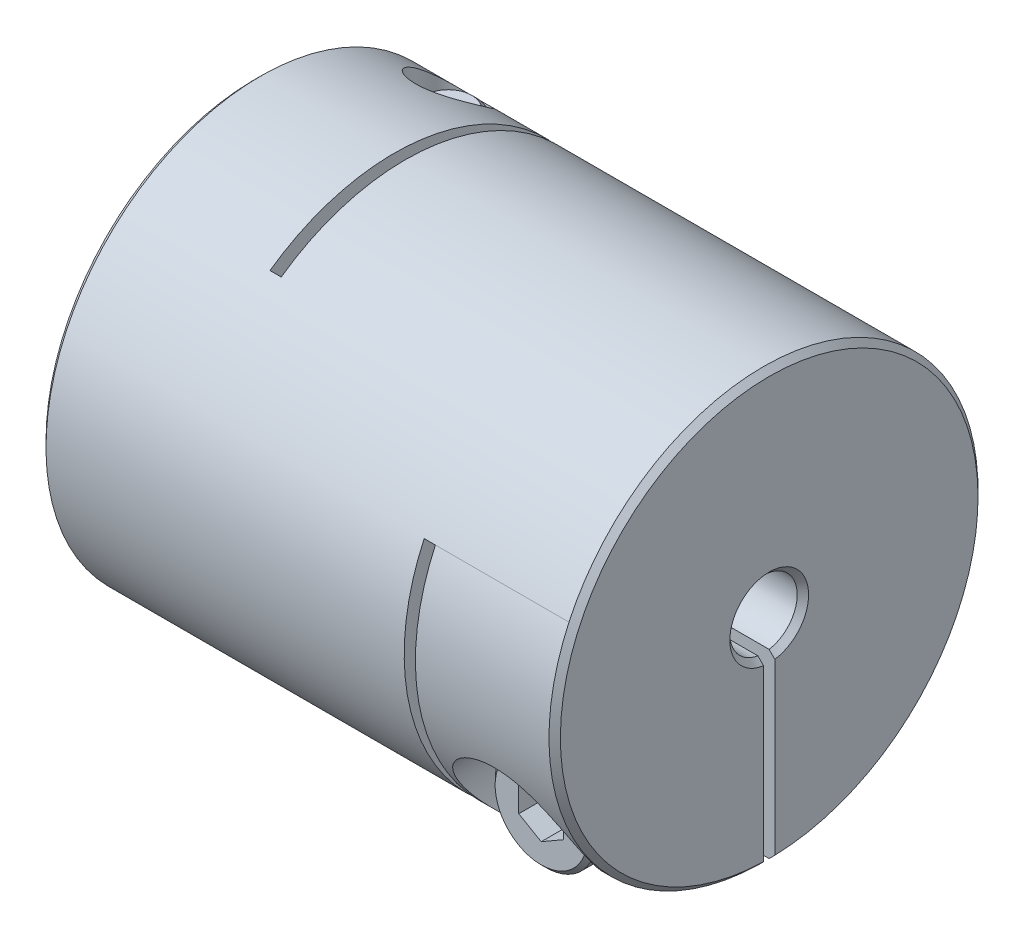
from build123d import *

# Parameters (mm, degrees)
SKETCH1_R                        = 9.55
BOSS_EXTRUDE1_DEPTH              = 11.45
SKETCH2_R                        = 1.5
CUT_EXTRUDE1_DEPTH               = 23.9
CHAMFER1_SIZE                    = 0.254
SKETCH4_W                        = 0.5
SKETCH4_H                        = 15.075
CUT_EXTRUDE2_DEPTH               = 20.1
SKETCH7_W                        = 0.5
SKETCH7_H                        = 13.575
CUT_EXTRUDE3_DEPTH               = 20.1
SKETCH8_W                        = 6.2
SKETCH8_H                        = 9.55
CUT_EXTRUDE5_DEPTH               = 0.25
SKETCH13_W                       = 6.2
SKETCH13_H                       = 9.55
CUT_EXTRUDE6_DEPTH               = 0.25
CBORE_FOR_M2_5_SHCS1_D           = 2.9
CBORE_FOR_M2_5_SHCS1_CBORE_D     = 5.5
CBORE_FOR_M2_5_SHCS1_CBORE_DEPTH = 5
CBORE_FOR_M2_5_SHCS2_D           = 2.9
CBORE_FOR_M2_5_SHCS2_CBORE_D     = 5.5
CBORE_FOR_M2_5_SHCS2_CBORE_DEPTH = 5
SKETCH16_R                       = 2.25
BOSS_EXTRUDE2_DEPTH              = 2.5
SKETCH17_R                       = 1.25
BOSS_EXTRUDE3_DEPTH              = 11.5
CHAMFER2_SIZE                    = 0.2
CUT_EXTRUDE7_DEPTH               = 1.5
CIRPATTERN1_COUNT                = 2
CIRPATTERN1_ANGLE                = 90


with BuildPart() as part:
    # Sketch1 → Boss-Extrude1 (new body, symmetric)
    with BuildSketch(Plane(origin=(0, 0, 0), x_dir=(0, 0, -1), z_dir=(1, 0, 0))):
        Circle(SKETCH1_R)
    extrude(amount=BOSS_EXTRUDE1_DEPTH, both=True)

    # Sketch2 → Cut-Extrude1 (cut, through all)
    with BuildSketch(Plane(origin=(11.45, 0, 0), x_dir=(0, 0, -1), z_dir=(1, 0, 0))):
        Circle(SKETCH2_R)
    extrude(amount=-CUT_EXTRUDE1_DEPTH, mode=Mode.SUBTRACT)

    # Chamfer1
    chamfer1_edges = [part.edges().sort_by_distance(p)[0] for p in [
        (-11.45, 0, 9.55),
        (11.45, 0, 9.55),
        (-11.45, 0, 1.5),
        (11.45, 0, 1.5),
    ]]
    chamfer(chamfer1_edges, length=CHAMFER1_SIZE)

    # Sketch4 → Cut-Extrude2 (cut, through all)
    with BuildSketch(Plane.XZ.offset(9.55)):
        with Locations((-5, -2.0125)):
            Rectangle(SKETCH4_W, SKETCH4_H)
    extrude(amount=-CUT_EXTRUDE2_DEPTH, mode=Mode.SUBTRACT)

    # Sketch7 → Cut-Extrude3 (cut, through all)
    with BuildSketch(Plane(origin=(0, 0, -9.55), x_dir=(-1, 0, 0), z_dir=(0, 0, -1))):
        with Locations((-5, -2.7625)):
            Rectangle(SKETCH7_W, SKETCH7_H)
    extrude(amount=-CUT_EXTRUDE3_DEPTH, mode=Mode.SUBTRACT)

    # Sketch8 → Cut-Extrude5 (cut, symmetric)
    with BuildSketch(Plane(origin=(0, 0, 0), x_dir=(1, 0, 0), z_dir=(0, 1, 0))):
        with Locations((-8.35, 4.775)):
            Rectangle(SKETCH8_W, SKETCH8_H)
    extrude(amount=CUT_EXTRUDE5_DEPTH, both=True, mode=Mode.SUBTRACT)

    # Sketch13 → Cut-Extrude6 (cut, symmetric)
    with BuildSketch(Plane.XY):
        with Locations((8.35, -4.775)):
            Rectangle(SKETCH13_W, SKETCH13_H)
    extrude(amount=CUT_EXTRUDE6_DEPTH, both=True, mode=Mode.SUBTRACT)

    # CBORE for M2.5 SHCS1 (through all)
    with Locations(Plane.XZ.offset(9.55)):
        with Locations((-8.35, -5.512873567)):
            CounterBoreHole(CBORE_FOR_M2_5_SHCS1_D / 2, CBORE_FOR_M2_5_SHCS1_CBORE_D / 2, CBORE_FOR_M2_5_SHCS1_CBORE_DEPTH)

    # CBORE for M2.5 SHCS2 (through all)
    with Locations(Plane.XY.offset(9.55)):
        with Locations((8.35, -5.512873567)):
            CounterBoreHole(CBORE_FOR_M2_5_SHCS2_D / 2, CBORE_FOR_M2_5_SHCS2_CBORE_D / 2, CBORE_FOR_M2_5_SHCS2_CBORE_DEPTH)


with BuildPart() as body_2:
    # Sketch16 → Boss-Extrude2 (new body)
    with BuildSketch(Plane.XY.offset(4.55)):
        with Locations((8.35, -5.512873567)):
            Circle(SKETCH16_R)
    extrude(amount=BOSS_EXTRUDE2_DEPTH)

    # Sketch17 → Boss-Extrude3 (add)
    with BuildSketch(Plane(origin=(0, 0, 4.55), x_dir=(-1, 0, 0), z_dir=(0, 0, -1))):
        with Locations(Location((-8.35, -5.512873567, 0), (0, 0, 180))):  # turned: the seam where the file's is
            Circle(SKETCH17_R)
    extrude(amount=BOSS_EXTRUDE3_DEPTH)

    # Chamfer2
    chamfer2_edges = [body_2.edges().sort_by_distance(p)[0] for p in [
        (6.1, -5.512873567, 4.55),
        (6.1, -5.512873567, 7.05),
        (7.1, -5.512873567, -6.95),
    ]]
    chamfer(chamfer2_edges, length=CHAMFER2_SIZE)

    # Sketch18 → Cut-Extrude7 (cut)
    with BuildSketch(Plane.XY.offset(7.05)):
        Polygon((8.35, -6.667574105), (9.35, -6.090223836), (9.35, -4.935523298), (8.35, -4.358173028), (7.35, -4.935523298), (7.35, -6.090223836), align=None)
    extrude(amount=-CUT_EXTRUDE7_DEPTH, mode=Mode.SUBTRACT)


with BuildPart() as body_3:
    # Mirror1: mirrored copy
    add(body_2.part.mirror(Plane(origin=(0, 0, 0), x_dir=(0, 0, 1), z_dir=(1, 0, 0))))


with BuildPart() as cirpattern1_1:
    # CirPattern1: pattern copy
    add(body_3.part.rotate(Axis((0, 0, 0), (1, 0, 0)), 1 * CIRPATTERN1_ANGLE / (CIRPATTERN1_COUNT - 1)))


solid = Compound([part.part, body_2.part, cirpattern1_1.part])
